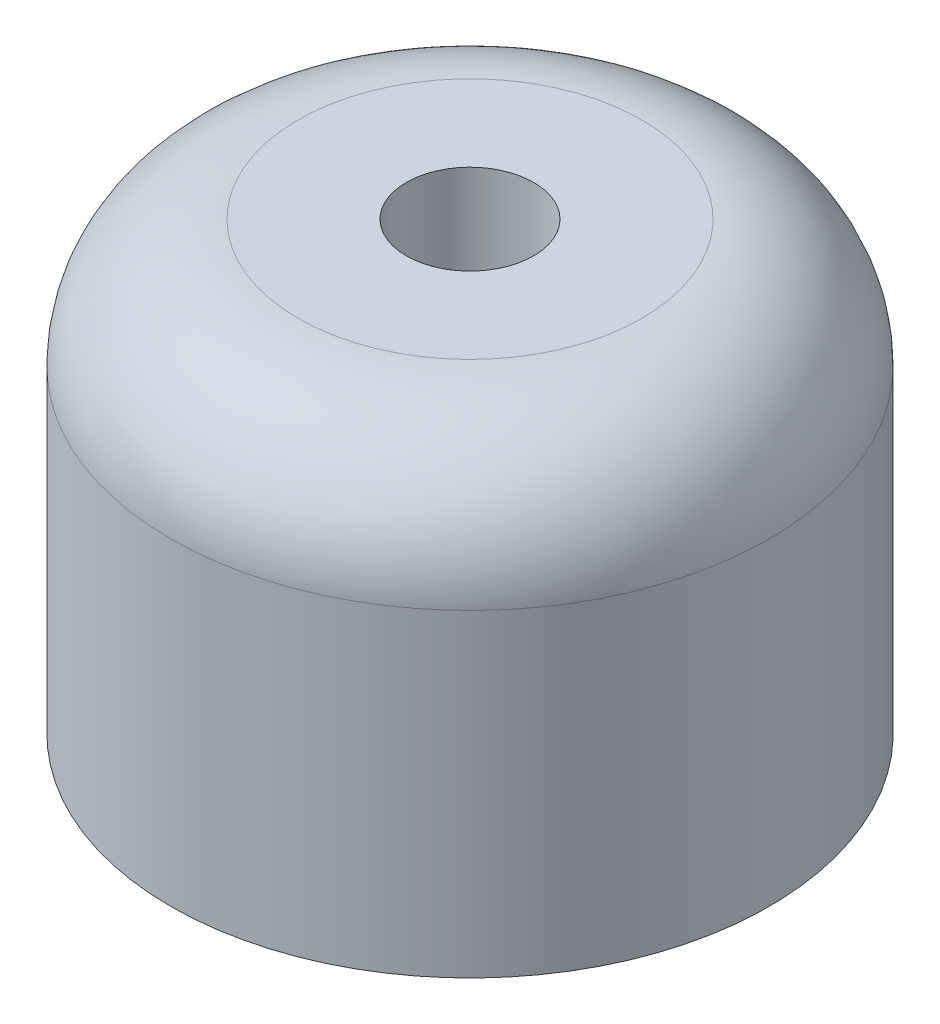
from build123d import *

# Parameters (mm, degrees)
SKETCH1_R           = 235
BOSS_EXTRUDE1_DEPTH = 350
SKETCH3_R           = 50
CUT_EXTRUDE1_DEPTH  = 250
FILLET1_R           = 100


with BuildPart() as part:
    # Sketch1 → Boss-Extrude1 (new body)
    with BuildSketch(Plane(origin=(0, 0, 0), x_dir=(1, 0, 0), z_dir=(0, 1, 0))):
        Circle(SKETCH1_R)
    extrude(amount=BOSS_EXTRUDE1_DEPTH)

    # Sketch3 → Cut-Extrude1 (cut)
    with BuildSketch(Plane(origin=(0, 350, 0), x_dir=(1, 0, 0), z_dir=(0, 1, 0))):
        Circle(SKETCH3_R)
    extrude(amount=-CUT_EXTRUDE1_DEPTH, mode=Mode.SUBTRACT)

    # Fillet1
    fillet1_edges = [part.edges().sort_by_distance(p)[0] for p in [
        (-235, 350, 0),
    ]]
    fillet(fillet1_edges, radius=FILLET1_R)


solid = part.part
